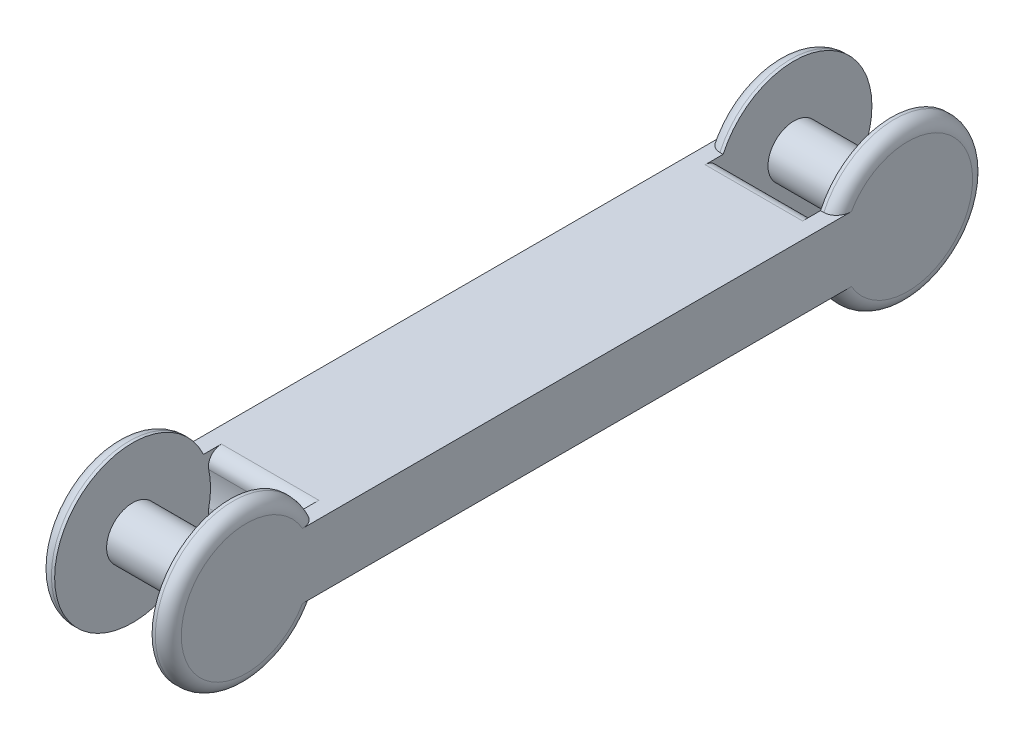
from build123d import *

# Parameters (mm, degrees)
BOSS_EXTRUDE1_DEPTH  = 20
CUT_EXTRUDE1_START   = -2.5
SKETCH2_R            = 12
SKETCH2_R_2          = 4
CUT_EXTRUDE1_DEPTH   = 15
FILLET1_R            = 2
FILLET1_OF_MIRROR1_R = 2


with BuildPart() as part:
    # Sketch1 → Boss-Extrude1 (new body)
    with BuildSketch(Plane(origin=(0, 0, 0), x_dir=(0, 0, -1), z_dir=(1, 0, 0))):
        with BuildLine():
            Line((0, 0), (-40, 0))
            ThreePointArc((-40, 0), (-62.908712115, -5), (-40, -10))
            Line((-40, -10), (0, -10))
            Line((0, -10), (0, 0))
        make_face()
    boss_extrude1 = extrude(amount=BOSS_EXTRUDE1_DEPTH)

    # Sketch2 → Cut-Extrude1 (cut)
    with BuildSketch(Plane(origin=(20, 0, 0), x_dir=(0, 0, -1), z_dir=(1, 0, 0)).offset(CUT_EXTRUDE1_START)):
        with Locations((-50.908712115, -5)):
            Circle(SKETCH2_R)
        with Locations((-50.908712115, -5)):
            Circle(SKETCH2_R_2, mode=Mode.SUBTRACT)
    cut_extrude1 = extrude(amount=-CUT_EXTRUDE1_DEPTH, mode=Mode.SUBTRACT)

    # Fillet1
    fillet1_edges = [part.edges().sort_by_distance(p)[0] for p in [
        (0, -5, 62.908712115),
        (20, -5, 62.908712115),
        (10, -10, 40),
        (10, 0, 40),
    ]]
    fillet(fillet1_edges, radius=FILLET1_R)

    # Mirror1: Boss-Extrude1, Cut-Extrude1 across plane
    add(boss_extrude1.mirror(Plane(origin=(20, -10, 0), x_dir=(1, 0, 0), z_dir=(0, 0, 1))))
    add(cut_extrude1.mirror(Plane(origin=(20, -10, 0), x_dir=(1, 0, 0), z_dir=(0, 0, 1))), mode=Mode.SUBTRACT)

    # Fillet1 of Mirror1
    fillet1_of_mirror1_edges = [part.edges().sort_by_distance(p)[0] for p in [
        (0, -5, -62.908712115),
        (20, -5, -62.908712115),
        (10, -10, -40),
        (10, 0, -40),
    ]]
    fillet(fillet1_of_mirror1_edges, radius=FILLET1_OF_MIRROR1_R)


solid = part.part
